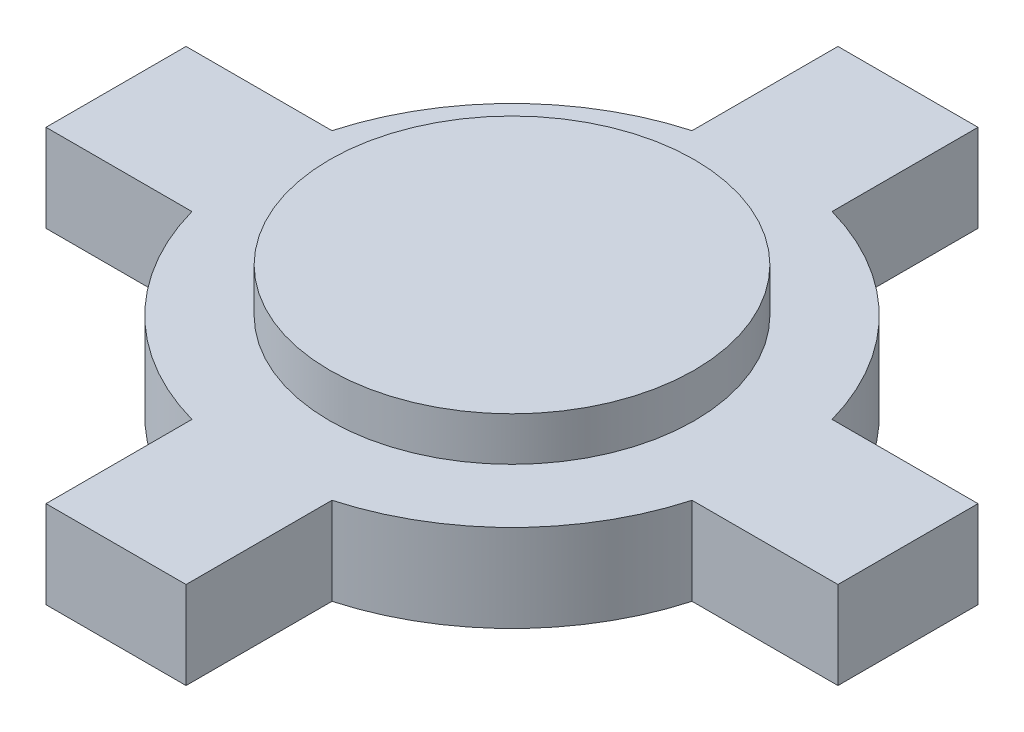
from build123d import *

# Parameters (mm, degrees)
EXTRUDE_1_DEPTH = 3
SKETCH_2_R      = 6.25
EXTRUDE_2_DEPTH = 1.5


with BuildPart() as part:
    # 草图1 → 凸台-拉伸1 (new body)
    with BuildSketch(Plane(origin=(0, 0, 0), x_dir=(1, 0, 0), z_dir=(0, 1, 0))):
        with BuildLine():
            Line((-13.570297544, 2.4), (-8.570297544, 2.4))
            ThreePointArc((-8.570297544, 2.4), (-6.293250353, 6.293250353), (-2.4, 8.570297544))
            Line((-2.4, 8.570297544), (-2.4, 13.570297544))
            Line((-2.4, 13.570297544), (2.4, 13.570297544))
            Line((2.4, 13.570297544), (2.4, 8.570297544))
            ThreePointArc((2.4, 8.570297544), (6.293250353, 6.293250353), (8.570297544, 2.4))
            Line((8.570297544, 2.4), (13.570297544, 2.4))
            Line((13.570297544, 2.4), (13.570297544, -2.4))
            Line((13.570297544, -2.4), (8.570297544, -2.4))
            ThreePointArc((8.570297544, -2.4), (6.293250353, -6.293250353), (2.4, -8.570297544))
            Line((2.4, -8.570297544), (2.4, -13.570297544))
            Line((2.4, -13.570297544), (-2.4, -13.570297544))
            Line((-2.4, -13.570297544), (-2.4, -8.570297544))
            ThreePointArc((-2.4, -8.570297544), (-6.293250353, -6.293250353), (-8.570297544, -2.4))
            Line((-8.570297544, -2.4), (-13.570297544, -2.4))
            Line((-13.570297544, -2.4), (-13.570297544, 2.4))
        make_face()
    extrude(amount=EXTRUDE_1_DEPTH)

    # 草图2 → 凸台-拉伸2 (add)
    with BuildSketch(Plane(origin=(0, 3, 0), x_dir=(1, 0, 0), z_dir=(0, 1, 0))):
        Circle(SKETCH_2_R)
    extrude(amount=EXTRUDE_2_DEPTH)


solid = part.part
